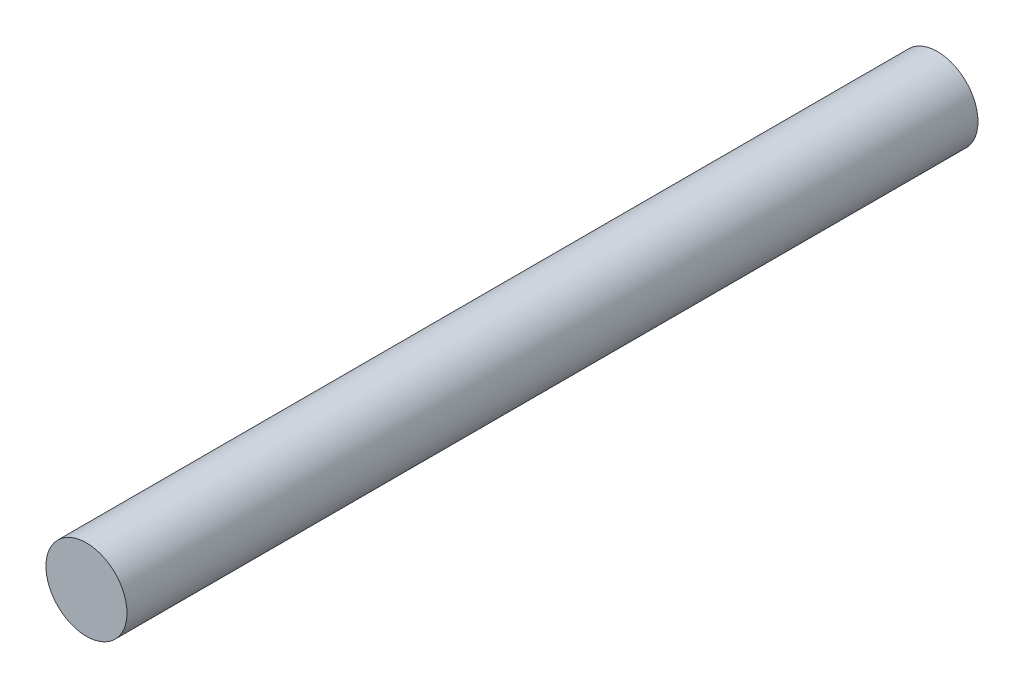
from build123d import *

# Parameters (mm, degrees)
SKETCH1_R           = 1
BOSS_EXTRUDE1_DEPTH = 10.5


with BuildPart() as part:
    # Sketch1 → Boss-Extrude1 (new body, symmetric)
    with BuildSketch(Plane.XY):
        Circle(SKETCH1_R)
    extrude(amount=BOSS_EXTRUDE1_DEPTH, both=True)


solid = part.part
